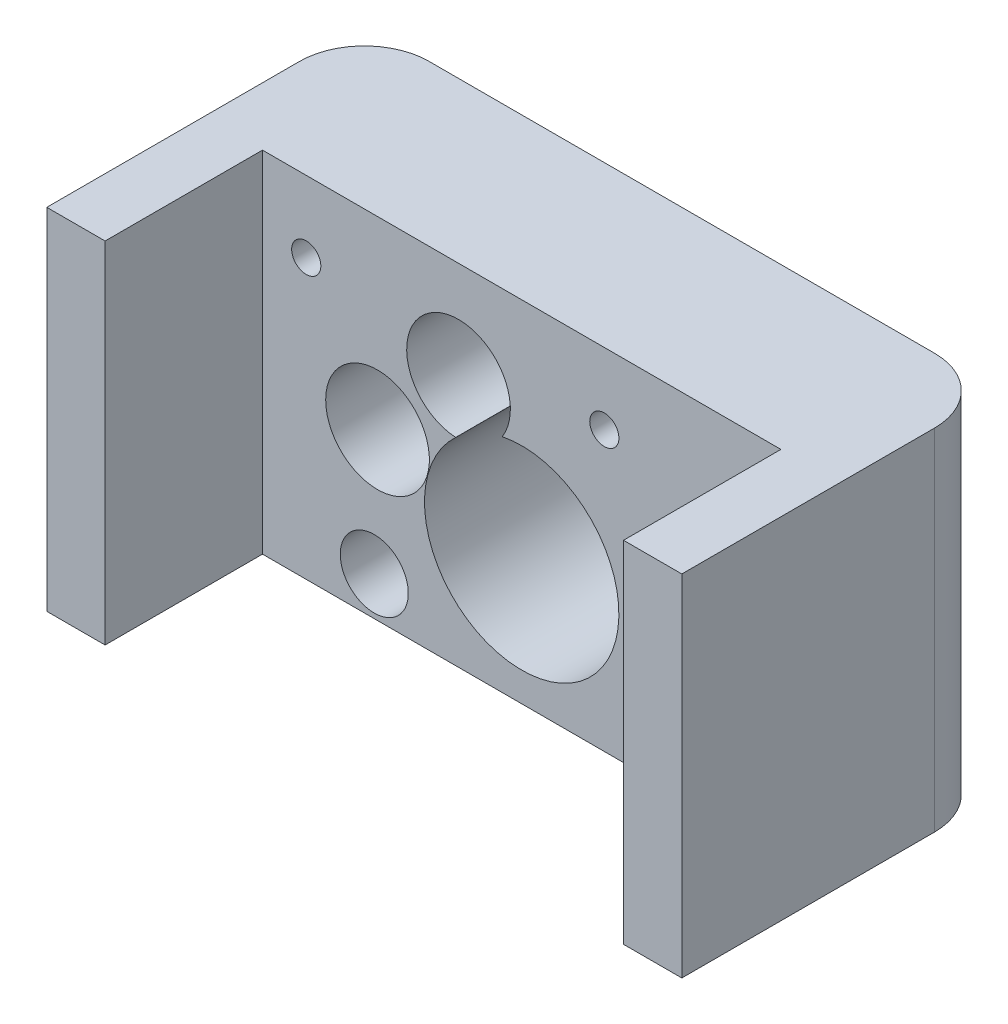
from build123d import *

# Parameters (mm, degrees)
SKETCH1_W           = 98
SKETCH1_H           = 54
SKETCH1_R           = 8
SKETCH1_R_2         = 5.25
SKETCH1_R_3         = 2.25
BOSS_EXTRUDE1_DEPTH = 49
FILLET1_R           = 10
SKETCH2_R           = 1.810942065
CUT_EXTRUDE1_DEPTH  = 145.300803777
SKETCH3_W           = 80.000000001
SKETCH3_H           = 24.290118096
CUT_EXTRUDE2_DEPTH  = 145.300803849


with BuildPart() as part:
    # Sketch1 → Boss-Extrude1 (new body)
    with BuildSketch(Plane.XY):
        with Locations((-75.521973847, 14.434233909)):
            Rectangle(SKETCH1_W, SKETCH1_H)
        with Locations((-97.771973847, 12.934233909)):
            Circle(SKETCH1_R, mode=Mode.SUBTRACT)
        with Locations((-108.771973847, 30.434233909)):
            Circle(SKETCH1_R_2, mode=Mode.SUBTRACT)
        with Locations((-98.271973847, -6.565766091)):
            Circle(SKETCH1_R_2, mode=Mode.SUBTRACT)
        with Locations((-62.771973847, 30.434233909)):
            Circle(SKETCH1_R_2, mode=Mode.SUBTRACT)
        with BuildLine():
            ThreePointArc((-78.528692534, 21.62979932), (-88.924408217, 33.051798322), (-85.70721761, 17.946082504))
            ThreePointArc((-85.70721761, 17.946082504), (-68.673659404, -6.411199365), (-78.528692534, 21.62979932))
        make_face(mode=Mode.SUBTRACT)
        with Locations((-62.771973847, 30.434233909)):
            Circle(SKETCH1_R_2)
        with Locations((-62.771973847, 30.434233909)):
            Circle(SKETCH1_R_3, mode=Mode.SUBTRACT)
        with Locations((-108.771973847, 30.434233909)):
            Circle(SKETCH1_R_2)
        with Locations((-108.771973847, 30.434233909)):
            Circle(SKETCH1_R_3, mode=Mode.SUBTRACT)
    extrude(amount=BOSS_EXTRUDE1_DEPTH)

    # Fillet1
    fillet1_edges = [part.edges().sort_by_distance(p)[0] for p in [
        (-124.521973847, 14.434233909, 0),
        (-26.521973847, 14.434233909, 0),
    ]]
    fillet(fillet1_edges, radius=FILLET1_R)

    # Sketch2 → Cut-Extrude1 (cut, through all)
    with BuildSketch(Plane(origin=(0, 41.434233909, 0), x_dir=(1, 0, 0), z_dir=(0, 1, 0))):
        with Locations(Location((-50.601973847, -39, 0), (0, 0, 270))):
            Circle(SKETCH2_R)
        with Locations(Location((-100.441973847, -39, 0), (0, 0, 270))):
            Circle(SKETCH2_R)
    extrude(amount=-CUT_EXTRUDE1_DEPTH, mode=Mode.SUBTRACT)

    # Sketch3 → Cut-Extrude2 (cut, through all)
    with BuildSketch(Plane.XZ.offset(12.565766091)):
        with Locations((-75.521627845, 36.854940952)):
            Rectangle(SKETCH3_W, SKETCH3_H)
    extrude(amount=-CUT_EXTRUDE2_DEPTH, mode=Mode.SUBTRACT)


solid = part.part
